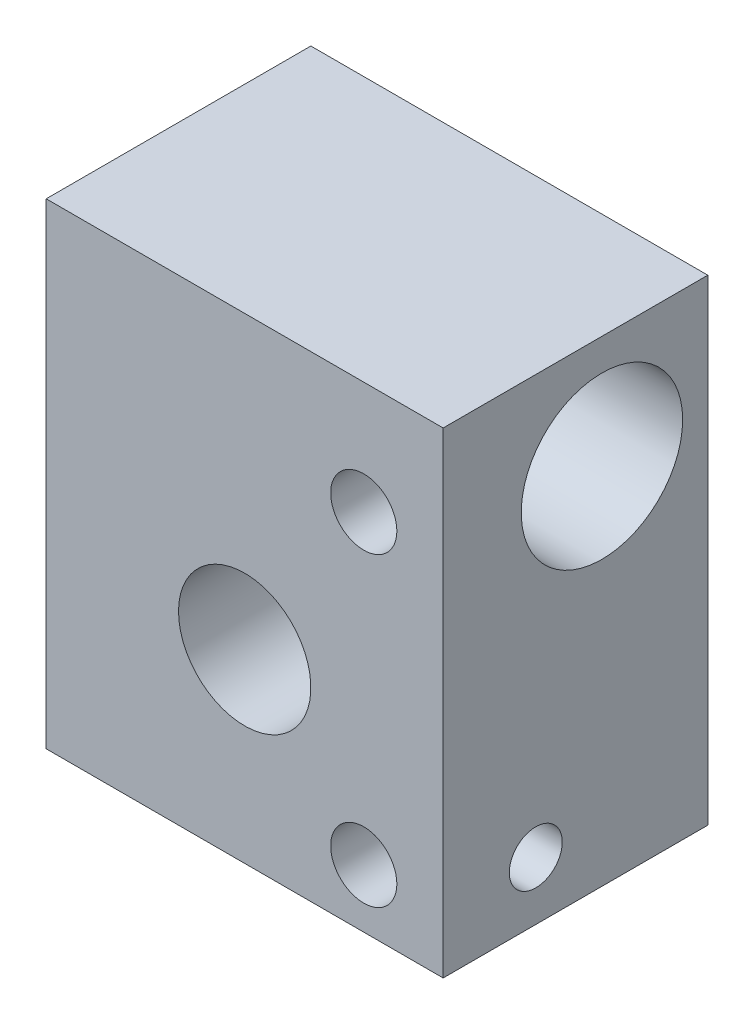
from build123d import *

# Parameters (mm, degrees)
SKETCH1_W                           = 15
SKETCH1_H                           = 18
BOSS_EXTRUDE1_DEPTH                 = 10
SKETCH2_R                           = 2.5
CUT_EXTRUDE1_DEPTH                  = 11
SKETCH3_R                           = 3.05
CUT_EXTRUDE2_DEPTH                  = 16
TALADRO_ROSCADO_M31_D               = 2.5
TALADRO_ROSCADO_M31_DEPTH           = 4
TALADRO_ROSCADO_M31_TIP             = 0.751075774
DI_METRO_DE_TALADRO_2_8_2_8_1_D     = 2
DI_METRO_DE_TALADRO_2_8_2_8_1_DEPTH = 12
DI_METRO_DE_TALADRO_2_8_2_8_1_TIP   = 0.600860619


with BuildPart() as part:
    # Sketch1 → Boss-Extrude1 (new body)
    with BuildSketch(Plane.XY):
        Rectangle(SKETCH1_W, SKETCH1_H)
    extrude(amount=BOSS_EXTRUDE1_DEPTH)

    # Sketch2 → Cut-Extrude1 (cut, through all)
    with BuildSketch(Plane(origin=(0, 0, 0), x_dir=(-1, 0, 0), z_dir=(0, 0, -1))):
        with Locations((0, -2)):
            Circle(SKETCH2_R)
    extrude(amount=-CUT_EXTRUDE1_DEPTH, mode=Mode.SUBTRACT)

    # Sketch3 → Cut-Extrude2 (cut, through all)
    with BuildSketch(Plane(origin=(7.5, 0, 0), x_dir=(0, 0, -1), z_dir=(1, 0, 0))):
        with Locations((-4, 4.75)):
            Circle(SKETCH3_R)
    extrude(amount=-CUT_EXTRUDE2_DEPTH, mode=Mode.SUBTRACT)

    # Taladro roscado M31
    with Locations(Plane(origin=(-2.648652683, -2.97524228, 10), x_dir=(1, 0, 0), z_dir=(0, 0, 1))):
        with Locations((7.148652683, 7.72524228), (7.148652683, -3.82475772)):
            Hole(TALADRO_ROSCADO_M31_D / 2, depth=TALADRO_ROSCADO_M31_DEPTH)
            with Locations((0, 0, -(TALADRO_ROSCADO_M31_DEPTH + TALADRO_ROSCADO_M31_TIP / 2))):  # 118° drill point
                Cone(0, TALADRO_ROSCADO_M31_D / 2, TALADRO_ROSCADO_M31_TIP, mode=Mode.SUBTRACT)

    # Diámetro de taladro Ø2.8 (2.8)1
    with Locations(Plane(origin=(7.5, -6.8, 6.5), x_dir=(0, 0, 1), z_dir=(1, 0, 0))):
        with Locations((0, 0)):
            Hole(DI_METRO_DE_TALADRO_2_8_2_8_1_D / 2, depth=DI_METRO_DE_TALADRO_2_8_2_8_1_DEPTH)
            with Locations((0, 0, -(DI_METRO_DE_TALADRO_2_8_2_8_1_DEPTH + DI_METRO_DE_TALADRO_2_8_2_8_1_TIP / 2))):  # 118° drill point
                Cone(0, DI_METRO_DE_TALADRO_2_8_2_8_1_D / 2, DI_METRO_DE_TALADRO_2_8_2_8_1_TIP, mode=Mode.SUBTRACT)


solid = part.part
